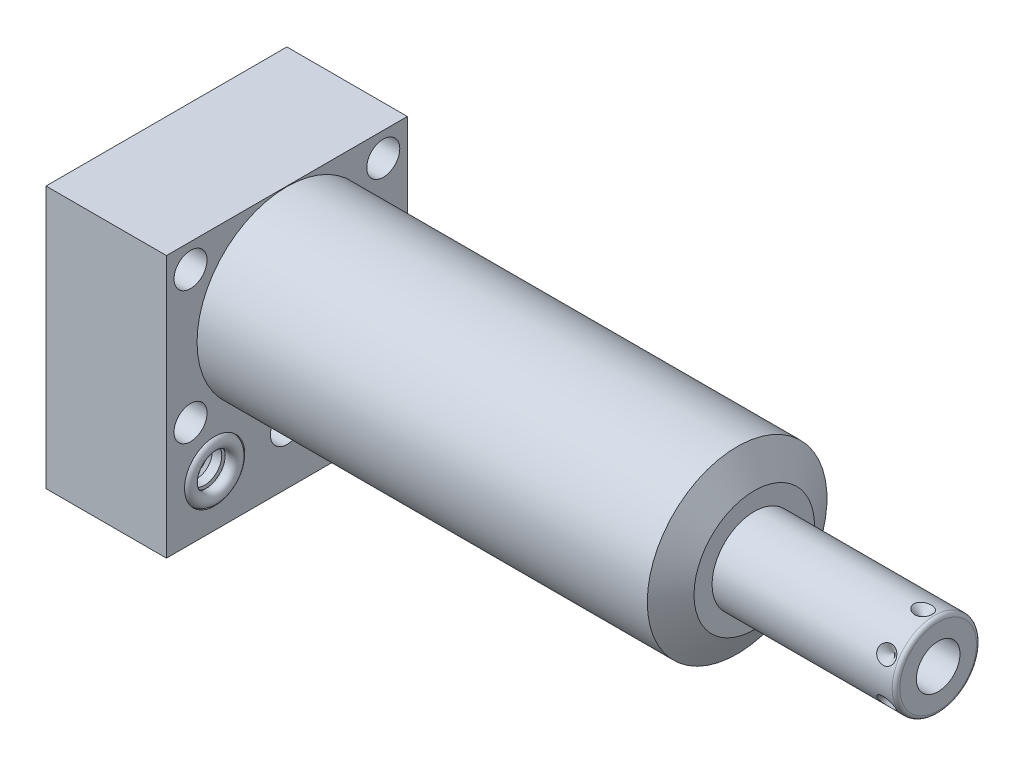
from build123d import *

# Parameters (mm, degrees)
SKETCH1_W           = 63.5
SKETCH1_H           = 69.088
EXTRUDE1_DEPTH      = 123.19
EXTRUDE1_DEPTH_BACK = 31.75
CUT_EXTRUDE1_REACH  = 125.19
SKETCH2_W           = 63.5
SKETCH2_H           = 69.088
SKETCH2_R           = 23.6855
SKETCH18_R          = 7.9375
CUT_EXTRUDE2_DEPTH  = 2.667
SKETCH19_R          = 7.9375
CUT_EXTRUDE3_DEPTH  = 2.667
SKETCH20_R          = 9.525
CUT_EXTRUDE4_DEPTH  = 0.254
SKETCH14_R          = 1.7653
SKETCH15_R          = 1.7653
CIRPATTERN1_COUNT   = 6
SKETCH21_W          = 4.3561
SKETCH21_H          = 31.75
HOLE1_AT_2_COUNT    = 2
HOLE1_AT_2_PITCH    = 54.58107178
HOLE1_AT_3_COUNT    = 2
HOLE1_AT_3_PITCH    = 34.9504
HOLE1_AT_4_COUNT    = 2
HOLE1_AT_4_PITCH    = 50.8
HOLE1_AT_5_COUNT    = 2
HOLE1_AT_5_PITCH    = 61.661742273
LPATTERN1_COUNT     = 2
LPATTERN1_PITCH     = 38.1


with BuildPart() as part:
    # Sketch1 → Extrude1 (new body, two sides)
    with BuildSketch(Plane(origin=(0, 0, 0), x_dir=(0, 0, -1), z_dir=(1, 0, 0))) as extrude1_sk:
        with Locations((0, -10.7188)):
            Rectangle(SKETCH1_W, SKETCH1_H)
    extrude(amount=EXTRUDE1_DEPTH)
    extrude(extrude1_sk.sketch, amount=-EXTRUDE1_DEPTH_BACK)

    # Sketch2 → Cut-Extrude1 (cut, up to next)
    with BuildSketch(Plane(origin=(0, 0, 0), x_dir=(0, 0, -1), z_dir=(1, 0, 0)), mode=Mode.PRIVATE) as cut_extrude1_sk1:
        with Locations((0, -10.7188)):
            Rectangle(SKETCH2_W, SKETCH2_H)
        Circle(SKETCH2_R, mode=Mode.SUBTRACT)
    cut_extrude1_tool1 = extrude(cut_extrude1_sk1.sketch, amount=CUT_EXTRUDE1_REACH, mode=Mode.PRIVATE) & part.part
    add(cut_extrude1_tool1.solids().sort_by_distance((0, 23.731363, 0))[0], mode=Mode.SUBTRACT)

    # Sketch3 → Cut-Revolve1 (revolve, cut)
    with BuildSketch(Plane.XY, mode=Mode.PRIVATE) as cut_revolve1_sk:
        Polygon((118.680605722, 23.6855), (123.19, 15.875), (123.19, 23.6855), align=None)
    revolve(cut_revolve1_sk.sketch.rotate(Axis((76.037136009, 0, 0), (1, 0, 0)), 90), axis=Axis((76.037136009, 0, 0), (1, 0, 0)), mode=Mode.SUBTRACT)  # turned: the seam where the file's is

    # S2D0002 → Cut-Revolve2 (revolve, cut)
    with BuildSketch(Plane(origin=(-29.083, -31.75, 19.05), x_dir=(0, 1, 0), z_dir=(0, 0, 1)), mode=Mode.PRIVATE) as cut_revolve2_sk:
        Polygon((0, 0), (4.5466, 0), (4.106586662, -2.0701), (3.4544, -2.722286662), (3.4544, -13.97), (0, -13.97), align=None)
    revolve(cut_revolve2_sk.sketch.rotate(Axis((-14.4145, -31.75, 19.05), (-1, 0, 0)), 90), axis=Axis((-14.4145, -31.75, 19.05), (-1, 0, 0)), mode=Mode.SUBTRACT)  # turned: the seam where the file's is

    # Sketch5 → Cut-Revolve3 (revolve, cut)
    with BuildSketch(Plane(origin=(-29.083, -31.75, -19.05), x_dir=(0, 1, 0), z_dir=(0, 0, 1)), mode=Mode.PRIVATE) as cut_revolve3_sk:
        Polygon((0, 0), (4.5466, 0), (4.106586662, -2.0701), (3.4544, -2.722286662), (3.4544, -13.97), (0, -13.97), align=None)
    revolve(cut_revolve3_sk.sketch.rotate(Axis((-14.4145, -31.75, -19.05), (-1, 0, 0)), 90), axis=Axis((-14.4145, -31.75, -19.05), (-1, 0, 0)), mode=Mode.SUBTRACT)  # turned: the seam where the file's is

    # Sketch6 → Cut-Revolve4 (revolve, cut)
    with BuildSketch(Plane(origin=(-2.667, -31.75, 19.05), x_dir=(0, -1, 0), z_dir=(0, 0, 1)), mode=Mode.PRIVATE) as cut_revolve4_sk:
        Polygon((0, 0), (4.5466, 0), (4.106586662, -2.0701), (3.4544, -2.722286662), (3.4544, -12.192), (0, -12.192), align=None)
    revolve(cut_revolve4_sk.sketch.rotate(Axis((-15.4686, -31.75, 19.05), (1, 0, 0)), 90), axis=Axis((-15.4686, -31.75, 19.05), (1, 0, 0)), mode=Mode.SUBTRACT)  # turned: the seam where the file's is

    # Sketch7 → Cut-Revolve5 (revolve, cut)
    with BuildSketch(Plane(origin=(-2.667, -31.75, -19.05), x_dir=(0, -1, 0), z_dir=(0, 0, 1)), mode=Mode.PRIVATE) as cut_revolve5_sk:
        Polygon((0, 0), (4.5466, 0), (4.106586662, -2.0701), (3.4544, -2.722286662), (3.4544, -12.192), (0, -12.192), align=None)
    revolve(cut_revolve5_sk.sketch.rotate(Axis((-15.4686, -31.75, -19.05), (1, 0, 0)), 90), axis=Axis((-15.4686, -31.75, -19.05), (1, 0, 0)), mode=Mode.SUBTRACT)  # turned: the seam where the file's is

    # Sketch8 → Cut-Revolve6 (revolve, cut)
    with BuildSketch(Plane(origin=(-15.875, -51.6128, 19.05), x_dir=(-1, 0, 0), z_dir=(0, 0, 1)), mode=Mode.PRIVATE) as cut_revolve6_sk:
        Polygon((0, -6.604), (6.1849, -6.604), (5.642306865, -9.1567), (4.9784, -9.820606865), (4.9784, -25.654), (0, -25.654), align=None)
    revolve(cut_revolve6_sk.sketch.rotate(Axis((-15.875, -24.9428, 19.05), (0, -1, 0)), 270), axis=Axis((-15.875, -24.9428, 19.05), (0, -1, 0)), mode=Mode.SUBTRACT)  # turned: the seam where the file's is

    # Sketch9 → Cut-Revolve7 (revolve, cut)
    with BuildSketch(Plane(origin=(-15.875, -51.6128, -19.05), x_dir=(-1, 0, 0), z_dir=(0, 0, 1)), mode=Mode.PRIVATE) as cut_revolve7_sk:
        Polygon((0, -6.604), (6.1849, -6.604), (5.642306865, -9.1567), (4.9784, -9.820606865), (4.9784, -25.654), (0, -25.654), align=None)
    revolve(cut_revolve7_sk.sketch.rotate(Axis((-15.875, -24.9428, -19.05), (0, -1, 0)), 270), axis=Axis((-15.875, -24.9428, -19.05), (0, -1, 0)), mode=Mode.SUBTRACT)  # turned: the seam where the file's is

    # Sketch18 → Cut-Extrude2 (cut)
    with BuildSketch(Plane(origin=(0, 0, 0), x_dir=(0, 0, -1), z_dir=(1, 0, 0))):
        with Locations((-19.05, -31.75)):
            Circle(SKETCH18_R)
        with Locations((19.05, -31.75)):
            Circle(SKETCH18_R)
    extrude(amount=-CUT_EXTRUDE2_DEPTH, mode=Mode.SUBTRACT)

    # Sketch19 → Cut-Extrude3 (cut)
    with BuildSketch(Plane.ZY.offset(31.75)):
        with Locations(Location((-19.05, -31.75, 0), (0, 0, 180))):  # turned: the seam where the file's is
            Circle(SKETCH19_R)
        with Locations(Location((19.05, -31.75, 0), (0, 0, 180))):  # turned: the seam where the file's is
            Circle(SKETCH19_R)
    extrude(amount=-CUT_EXTRUDE3_DEPTH, mode=Mode.SUBTRACT)

    # Sketch20 → Cut-Extrude4 (cut)
    with BuildSketch(Plane.XZ.offset(45.2628)):
        with Locations(Location((-15.875, -19.05, 0), (0, 0, 270))):  # turned: the seam where the file's is
            Circle(SKETCH20_R)
        with Locations(Location((-15.875, 19.05, 0), (0, 0, 270))):  # turned: the seam where the file's is
            Circle(SKETCH20_R)
    extrude(amount=-CUT_EXTRUDE4_DEPTH, mode=Mode.SUBTRACT)

    # Sketch10 → Revolve1 (revolve)
    with BuildSketch(Plane.XY, mode=Mode.PRIVATE) as revolve1_sk:
        with BuildLine():
            Line((123.19, 0), (123.19, 11.1125))
            Line((123.19, 11.1125), (170.6626, 11.1125))
            ThreePointArc((170.6626, 11.1125), (171.38102049, 10.81492049), (171.6786, 10.0965))
            Line((171.6786, 10.0965), (171.6786, 0))
            Line((171.6786, 0), (123.19, 0))
        make_face()
    revolve(revolve1_sk.sketch.rotate(Axis((58.270820274, 0, 0), (1, 0, 0)), 90), axis=Axis((58.270820274, 0, 0), (1, 0, 0)))  # turned: the seam where the file's is

    # S2D0001 → Cut-Revolve8 (revolve, cut)
    with BuildSketch(Plane(origin=(118.6434, -5.7531, 0), x_dir=(0, -1, 0), z_dir=(0, 0, 1)), mode=Mode.PRIVATE) as cut_revolve8_sk:
        Polygon((0, 53.0352), (0, 36.0172), (-5.7531, 32.560388773), (-5.7531, 53.0352), align=None)
    revolve(cut_revolve8_sk.sketch.rotate(Axis((84.296273767, 0, 0), (1, 0, 0)), 270), axis=Axis((84.296273767, 0, 0), (1, 0, 0)), mode=Mode.SUBTRACT)  # turned: the seam where the file's is

    # Sketch16 → Cut-Revolve9 (revolve, cut)
    with BuildSketch(Plane(origin=(114.681, -11.1125, 0), x_dir=(-1, 0, 0), z_dir=(0, 0, 1)), mode=Mode.PRIVATE) as cut_revolve9_sk:
        Polygon((-53.0352, 0), (-50.6222, 0), (-53.0352, -2.413), align=None)
    cut_revolve9 = revolve(cut_revolve9_sk.sketch.rotate(Axis((167.7162, -6.093194843, 0), (0, -1, 0)), 90), axis=Axis((167.7162, -6.093194843, 0), (0, -1, 0)), mode=Mode.SUBTRACT)  # turned: the seam where the file's is

    # CirPattern1: Cut-Revolve9 ×6 about axis
    cirpattern1_axis = Axis((0, 0, 0), (-1, 0, 0))
    for i in range(1, CIRPATTERN1_COUNT):
        add(cut_revolve9.rotate(cirpattern1_axis, i * 360 / CIRPATTERN1_COUNT), mode=Mode.SUBTRACT)

    # Sketch21 → Hole1 (revolve, cut)
    with BuildSketch(Plane(origin=(0, 17.4752, 25.4), x_dir=(0, 0, -1), z_dir=(0, 1, 0))):
        with Locations((2.17805, 15.875)):
            Rectangle(SKETCH21_W, SKETCH21_H)
    hole1 = revolve(axis=Axis((-110, 17.4752, 25.4), (1, 0, 0)), mode=Mode.SUBTRACT)

    # Hole1 at 2: Hole1 ×2
    with Locations(*[Vector(0, -0.885120032, -0.465362793) * (i * HOLE1_AT_2_PITCH) for i in range(1, HOLE1_AT_2_COUNT)]):
        add(hole1, mode=Mode.SUBTRACT)

    # Hole1 at 3: Hole1 ×2
    with Locations(*[(0, -i * HOLE1_AT_3_PITCH, 0) for i in range(1, HOLE1_AT_3_COUNT)]):
        add(hole1, mode=Mode.SUBTRACT)

    # Hole1 at 4: Hole1 ×2
    with Locations(*[(0, 0, -i * HOLE1_AT_4_PITCH) for i in range(1, HOLE1_AT_4_COUNT)]):
        add(hole1, mode=Mode.SUBTRACT)

    # Hole1 at 5: Hole1 ×2
    with Locations(*[Vector(0, -0.566808506, -0.823849572) * (i * HOLE1_AT_5_PITCH) for i in range(1, HOLE1_AT_5_COUNT)]):
        add(hole1, mode=Mode.SUBTRACT)


with BuildPart() as body_2:
    # Sketch14 → Revolve2 (revolve)
    with BuildSketch(Plane(origin=(0, -31.75, -19.05), x_dir=(0, 0, -1), z_dir=(0, -1, 0)), mode=Mode.PRIVATE) as revolve2_sk:
        with Locations((6.1722, -0.9017)):
            Circle(SKETCH14_R)
    revolve2 = revolve(revolve2_sk.sketch.rotate(Axis((-2.84353, -31.75, -19.05), (1, 0, 0)), 180), axis=Axis((-2.84353, -31.75, -19.05), (1, 0, 0)))  # turned: the seam where the file's is


with BuildPart() as body_3:
    # Sketch15 → Revolve3 (revolve)
    with BuildSketch(Plane(origin=(0, -31.75, -19.05), x_dir=(0, 0, -1), z_dir=(0, -1, 0)), mode=Mode.PRIVATE) as revolve3_sk:
        with Locations((6.1722, -30.8483)):
            Circle(SKETCH15_R)
    revolve3 = revolve(revolve3_sk.sketch.rotate(Axis((-32.79013, -31.75, -19.05), (1, 0, 0)), 180), axis=Axis((-32.79013, -31.75, -19.05), (1, 0, 0)))  # turned: the seam where the file's is


with BuildPart() as lpattern1_1:
    # LPattern1: Revolve2, Revolve3 ×2
    with Locations(*[(0, 0, i * LPATTERN1_PITCH) for i in range(1, LPATTERN1_COUNT)]):
        add(revolve2)
        add(revolve3)


solid = Compound([part.part, body_2.part, body_3.part, lpattern1_1.part])
